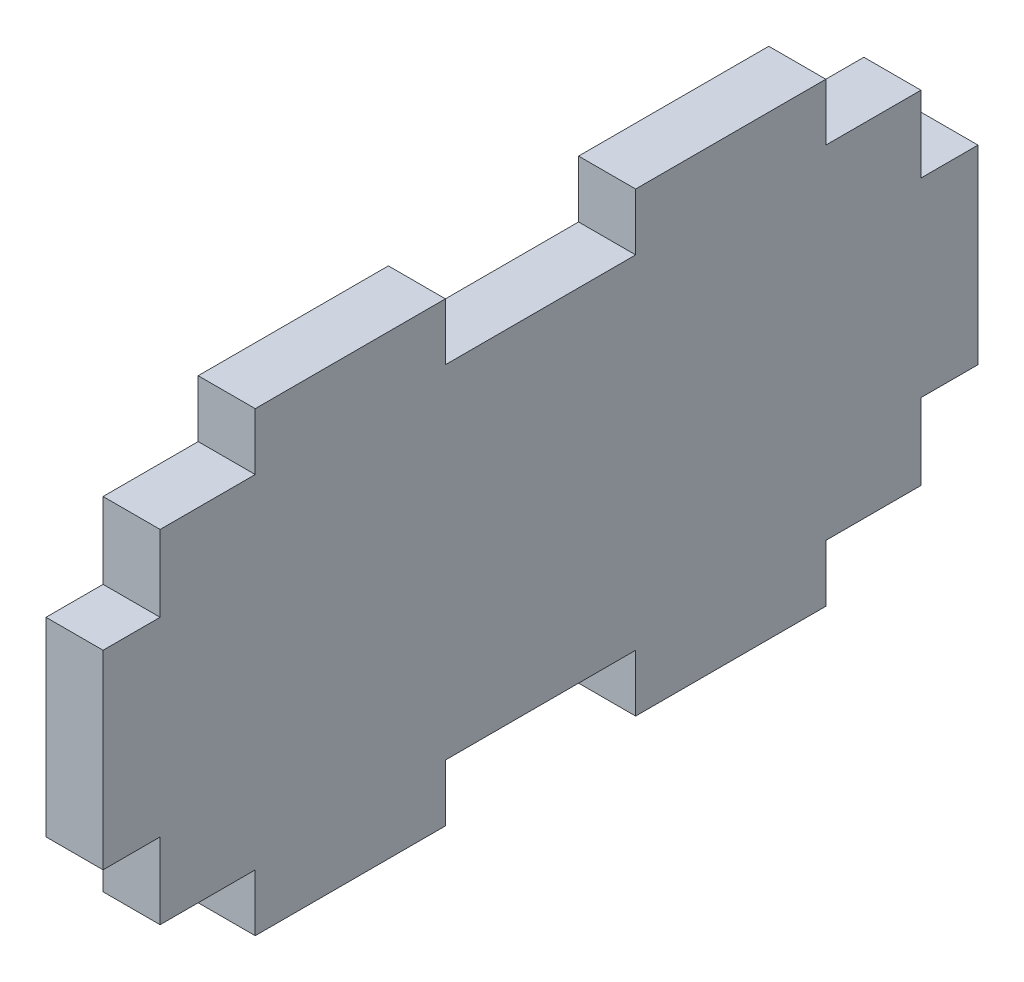
from build123d import *

# Parameters (mm, degrees)
SKETCH1_W               = 46
SKETCH1_H               = 24
BOSS_EXTRUDE1_DEPTH     = 3
SKETCH2_W               = 5
SKETCH2_H               = 3
CUT_EXTRUDE1_DEPTH      = 4
MIRROR2_COPY_1_SKETCH_W = 5
MIRROR2_COPY_1_SKETCH_H = 3
MIRROR2_COPY_1_DEPTH    = 4


with BuildPart() as part:
    # Sketch1 → Boss-Extrude1 (new body)
    with BuildSketch(Plane(origin=(0, 0, 0), x_dir=(0, 0, -1), z_dir=(1, 0, 0))):
        Rectangle(SKETCH1_W, SKETCH1_H)
    extrude(amount=BOSS_EXTRUDE1_DEPTH)

    # Sketch2 → Cut-Extrude1 (cut, through all)
    with BuildSketch(Plane(origin=(3, 0, 0), x_dir=(0, 0, -1), z_dir=(1, 0, 0))):
        Polygon((23, 5), (20, 5), (20, 9), (15, 9), (15, 12), (23, 12), align=None)
        with Locations((2.5, 10.5)):
            Rectangle(SKETCH2_W, SKETCH2_H)
    cut_extrude1 = extrude(amount=-CUT_EXTRUDE1_DEPTH, mode=Mode.SUBTRACT)

    # Mirror1: Cut-Extrude1 across plane
    add(cut_extrude1.mirror(Plane.ZX), mode=Mode.SUBTRACT)

    # Mirror2: Cut-Extrude1 across plane
    add(cut_extrude1.mirror(Plane.XY), mode=Mode.SUBTRACT)

    # Mirror2 copy 1 sketch → Mirror2 copy 1 (cut, through all)
    with BuildSketch(Plane(origin=(3, 0, 0), x_dir=(0, 0, 1), z_dir=(1, 0, 0))):
        Polygon((23, 5), (20, 5), (20, 9), (15, 9), (15, 12), (23, 12), align=None)
        with Locations((2.5, 10.5)):
            Rectangle(MIRROR2_COPY_1_SKETCH_W, MIRROR2_COPY_1_SKETCH_H)
    extrude(amount=-MIRROR2_COPY_1_DEPTH, mode=Mode.SUBTRACT)


solid = part.part
